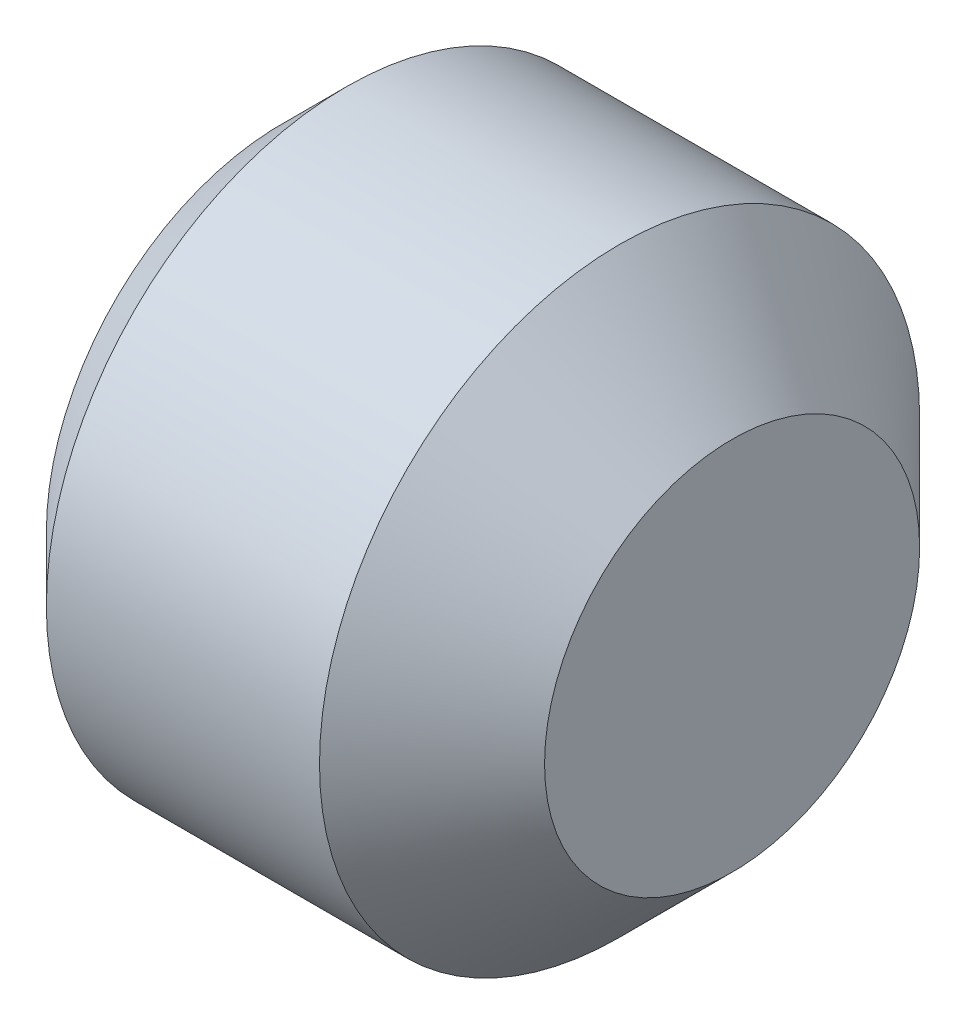
from build123d import *

# Parameters (mm, degrees)
CUT_EXTRUDE_1_DEPTH = 1.5


with BuildPart() as part:
    # ｽｹｯﾁ1 → 回転1 (revolve)
    with BuildSketch(Plane.XY):
        Polygon((-3, 0), (-3, 1.5705), (-2.5705, 2), (-0.75, 2), (0, 1.25), (0, 0), align=None)
    revolve(axis=Axis((0, 0, 0), (-1, 0, 0)))

    # ｽｹｯﾁ2 → ｶｯﾄ - 押し出し1 (cut)
    with BuildSketch(Plane.ZY.offset(3)):
        Polygon((0.577350269, -1), (1.154700538, 0), (0.577350269, 1), (-0.577350269, 1), (-1.154700538, 0), (-0.577350269, -1), align=None)
    extrude(amount=-CUT_EXTRUDE_1_DEPTH, mode=Mode.SUBTRACT)

    # ｽｹｯﾁ3 → ｶｯﾄ - 回転1 (revolve, cut)
    with BuildSketch(Plane.XY):
        Polygon((-1.5, 0), (-1.5, 1), (-0.922649731, 0), align=None)
    revolve(axis=Axis((-0.922649731, 0, 0), (-1, 0, 0)), mode=Mode.SUBTRACT)


solid = part.part
